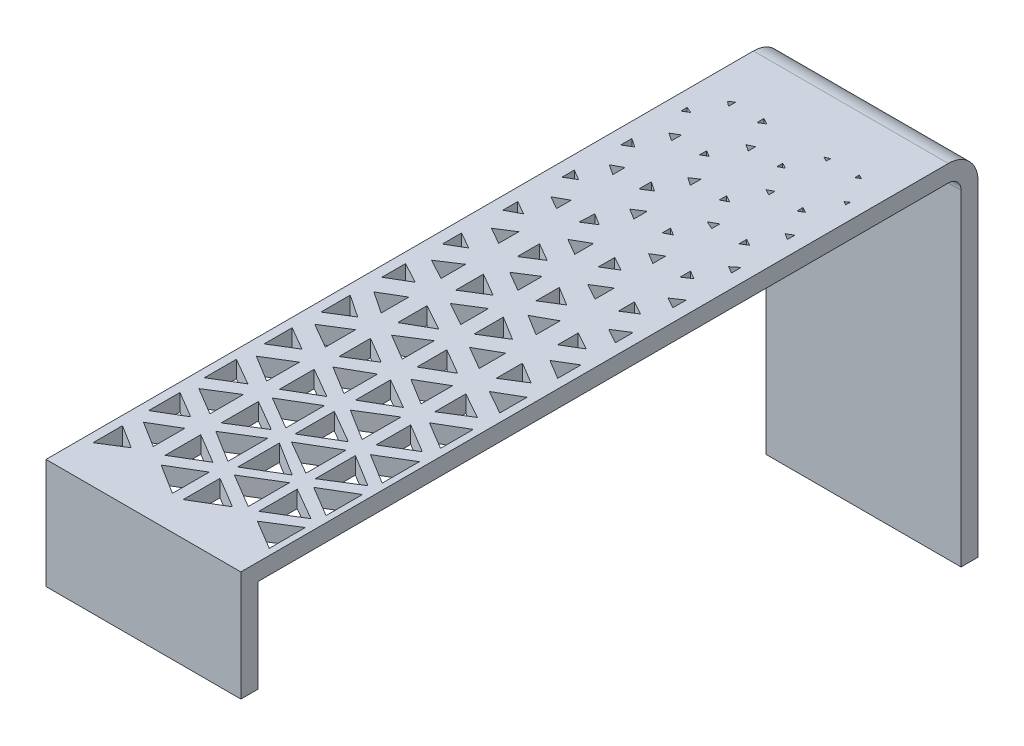
from build123d import *

# Parameters (mm, degrees)
SKETCH1_W           = 23
SKETCH1_H           = 87
BOSS_EXTRUDE1_DEPTH = 42
FILLET1_R           = 3.5
CUT_EXTRUDE1_DEPTH  = 24
SKETCH3_W           = 2
SKETCH3_H           = 40
CUT_EXTRUDE3_DEPTH  = 24
SKETCH4_W           = 83
SKETCH4_H           = 2
CUT_EXTRUDE5_DEPTH  = 24
SKETCH6_W           = 23
SKETCH6_H           = 2
BOSS_EXTRUDE2_DEPTH = 11
CUT_EXTRUDE6_DEPTH  = 2


with BuildPart() as part:
    # Sketch1 → Boss-Extrude1 (new body)
    with BuildSketch(Plane(origin=(0, 0, 0), x_dir=(1, 0, 0), z_dir=(0, 1, 0))):
        with Locations((14.807125307, -11.663390663)):
            Rectangle(SKETCH1_W, SKETCH1_H)
    extrude(amount=BOSS_EXTRUDE1_DEPTH)

    # Fillet1
    fillet1_edges = [part.edges().sort_by_distance(p)[0] for p in [
        (14.807125307, 42, -31.836609337),
    ]]
    fillet(fillet1_edges, radius=FILLET1_R)

    # Sketch2 → Cut-Extrude1 (cut, through all)
    with BuildSketch(Plane(origin=(26.307125307, 0, 0), x_dir=(0, 0, -1), z_dir=(1, 0, 0))):
        with BuildLine():
            Line((29.836609337, 2), (29.836609337, 38.5))
            ThreePointArc((29.836609337, 38.5), (29.397269508, 39.560660172), (28.336609337, 40))
            Line((28.336609337, 40), (-53.163390663, 40))
            Line((-53.163390663, 40), (-53.163390663, 2))
            Line((-53.163390663, 2), (29.836609337, 2))
        make_face()
    extrude(amount=-CUT_EXTRUDE1_DEPTH, mode=Mode.SUBTRACT)

    # Sketch3 → Cut-Extrude3 (cut, through all)
    with BuildSketch(Plane(origin=(26.307125307, 0, 0), x_dir=(0, 0, -1), z_dir=(1, 0, 0))):
        with Locations((-54.163390663, 20)):
            Rectangle(SKETCH3_W, SKETCH3_H)
    extrude(amount=-CUT_EXTRUDE3_DEPTH, mode=Mode.SUBTRACT)

    # Sketch4 → Cut-Extrude5 (cut, through all)
    with BuildSketch(Plane(origin=(26.307125307, 0, 0), x_dir=(0, 0, -1), z_dir=(1, 0, 0))):
        with Locations((-11.663390663, 1)):
            Rectangle(SKETCH4_W, SKETCH4_H)
    extrude(amount=-CUT_EXTRUDE5_DEPTH, mode=Mode.SUBTRACT)

    # Sketch6 → Boss-Extrude2 (add)
    with BuildSketch(Plane.XZ.offset(-40)):
        with Locations((14.807125307, 54.163390663)):
            Rectangle(SKETCH6_W, SKETCH6_H)
    extrude(amount=BOSS_EXTRUDE2_DEPTH)

    # Sketch7 → Cut-Extrude6 (cut)
    with BuildSketch(Plane(origin=(0, 42, 0), x_dir=(1, 0, 0), z_dir=(0, 1, 0))):
        Polygon((4.373025741, -47.203860784), (4.373025741, -50.681960926), (7.147007879, -48.942910855), align=None)
        Polygon((10.680131891, -48.942910855), (14.240933111, -51.175229345), (14.240933111, -46.82714285), align=None)
        Polygon((15.507728284, -46.82714285), (15.507728284, -51.175229345), (19.151354833, -49.001186097), align=None)
        Polygon((22.09300933, -49.001186097), (25.574659446, -51.07858284), (25.574659446, -46.82714285), align=None)
        Polygon((16.017628639, -45.639114235), (20.057709924, -48.049710194), (20.057709924, -43.18389932), align=None)
        Polygon((21.173055855, -43.380049704), (21.173055855, -47.914164474), (25.007184217, -45.584110082), align=None)
        Polygon((21.962994751, -42.225962076), (25.574659446, -44.380934638), (25.574659446, -40.076637523), align=None)
        Polygon((19.434683019, -42.225962076), (15.401886771, -44.625904685), (15.401886771, -39.716859283), align=None)
        Polygon((14.240933111, -39.918335097), (14.240933111, -44.625904685), (10.457774241, -42.272119891), align=None)
        Polygon((9.91671328, -43.504598698), (9.91671328, -47.715752756), (13.454865862, -45.610175727), align=None)
        Polygon((8.322220146, -43.797001873), (8.322220146, -47.517808673), (5.256146085, -45.610175727), align=None)
        Polygon((4.373025741, -44.11682065), (7.492411749, -42.272119891), (4.373025741, -40.415753505), align=None)
        Polygon((5.085620013, -38.905182774), (8.322220146, -40.831304028), (8.322220146, -36.877680696), align=None)
        Polygon((9.91671328, -36.705858486), (9.91671328, -41.095227494), (13.555107042, -38.81603), align=None)
        Polygon((16.017628639, -38.90054299), (20.057709924, -41.243682573), (20.057709924, -36.511788955), align=None)
        Polygon((21.173055855, -36.511788955), (21.173055855, -41.243682573), (24.987036337, -38.854492362), align=None)
        Polygon((21.962994751, -35.530278609), (25.574659446, -37.748711352), (25.574659446, -33.364914894), align=None)
        Polygon((21.303013305, -30.113244689), (21.303013305, -34.213632441), (24.722583325, -32.163438565), align=None)
        Polygon((22.195258476, -28.798102187), (25.460090465, -30.7555233), (25.460090465, -26.874007414), align=None)
        Polygon((21.381965145, -23.686139656), (21.381965145, -27.35601413), (24.481102368, -25.414622886), align=None)
        Polygon((22.521772744, -22.063157282), (25.343157928, -23.63672974), (25.343157928, -20.423731912), align=None)
        Polygon((21.587169292, -17.207284348), (21.587169292, -20.302378453), (24.112880255, -18.720198383), align=None)
        Polygon((22.931533756, -15.31095683), (25.219081627, -16.68120993), (25.219081627, -13.929664465), align=None)
        Polygon((21.78999441, -10.835620554), (21.78999441, -13.260888891), (23.889941826, -11.9928755), align=None)
        Polygon((23.21476035, -8.661215667), (24.987036337, -9.637894958), (24.987036337, -7.541574983), align=None)
        Polygon((21.928662612, -4.335679353), (21.928662612, -6.232617986), (23.523557392, -5.225038412), align=None)
        Polygon((23.523557392, -1.958181357), (24.799839179, -2.669872676), (24.799839179, -1.098028134), align=None)
        Polygon((22.09300933, 2.118032404), (22.09300933, 0.878569452), (23.080046096, 1.543785289), align=None)
        Polygon((23.889941826, 4.819093406), (24.708514938, 4.342856588), (24.708514938, 5.478257439), align=None)
        Polygon((22.167753982, 8.668240856), (22.167753982, 7.762275795), (22.953283382, 8.236602814), align=None)
        Polygon((24.578926953, 11.942487098), (24.578926953, 11.072115254), (23.855167384, 11.522419966), align=None)
        Polygon((22.233407626, 15.253053083), (22.233407626, 14.533509909), (22.863017669, 14.898933035), align=None)
        Polygon((24.041063021, 18.282077068), (24.481102368, 18.034579818), (24.481102368, 18.578642659), align=None)
        Polygon((22.233407626, 21.887378083), (22.233407626, 21.367412528), (22.743245051, 21.664075736), align=None)
        Polygon((19.003489762, 8.668240856), (19.003489762, 7.716775297), (18.028465045, 8.143823796), align=None)
        Polygon((16.519261051, 11.942487098), (16.519261051, 11.072115254), (17.328382384, 11.507301176), align=None)
        Polygon((18.240332563, 14.898933035), (18.919747111, 14.533509909), (18.919747111, 15.253053083), align=None)
        Polygon((16.519261051, 18.578642659), (16.519261051, 17.900689216), (17.169621622, 18.239665938), align=None)
        Polygon((18.861553538, 21.887378083), (18.861553538, 21.367412528), (18.335711671, 21.641488417), align=None)
        Polygon((16.519261051, 5.335788562), (16.519261051, 4.342856588), (17.39552653, 4.799578002), align=None)
        Polygon((19.096098834, 2.195416157), (19.096098834, 0.664455817), (17.845165156, 1.429935987), align=None)
        Polygon((16.228614858, -0.970191589), (16.228614858, -2.901459417), (17.894943581, -1.881787777), align=None)
        Polygon((17.39552653, -5.31212693), (19.32916594, -6.369960411), (19.32916594, -4.113548418), align=None)
        Polygon((10.389248968, -35.530278609), (14.240933111, -37.791834388), (14.240933111, -33.234007387), align=None)
        Polygon((16.017628639, -7.293535955), (16.017628639, -10.037863963), (18.252009038, -8.652869263), align=None)
        Polygon((15.401886771, -33.234007387), (15.401886771, -37.86277333), (19.343446158, -35.512920887), align=None)
        Polygon((4.306147659, -33.691236831), (4.306147659, -37.47024358), (7.492411749, -35.530278609), align=None)
        Polygon((9.91671328, -34.213632441), (13.454865862, -32.163438565), (9.91671328, -30.121294465), align=None)
        Polygon((8.322220146, -30.264520369), (8.322220146, -34.132852243), (5.1676151, -32.198686306), align=None)
        Polygon((4.373025741, -27.176559978), (4.373025741, -30.486967872), (7.147007879, -28.786171201), align=None)
        Polygon((19.930328421, -29.876058228), (19.930328421, -34.475602674), (16.228614858, -32.163438565), align=None)
        Polygon((15.507728284, -26.695064873), (15.507728284, -30.843252154), (19.096098834, -28.763959316), align=None)
        Polygon((14.149392865, -26.874007414), (14.149392865, -30.843252154), (10.794314675, -28.786171201), align=None)
        Polygon((19.771131554, -23.63672974), (19.771131554, -27.35601413), (16.655256244, -25.445594346), align=None)
        Polygon((15.752445363, -20.302378453), (15.752445363, -23.83714891), (18.796870014, -22.069763682), align=None)
        Polygon((16.852340946, -18.720198383), (19.577738856, -20.302378453), (19.577738856, -17.163959593), align=None)
        Polygon((15.752445363, -13.629405346), (15.752445363, -17.098387514), (18.559407138, -15.36389643), align=None)
        Polygon((19.482614442, -10.655702339), (19.482614442, -13.506041775), (17.033827053, -11.9928755), align=None)
        Polygon((10.081927259, -23.63672974), (10.081927259, -27.35601413), (13.159201825, -25.454490089), align=None)
        Polygon((11.007541373, -22.069763682), (14.084815939, -23.887524031), (14.084815939, -20.115663305), align=None)
        Polygon((10.081927259, -16.957013986), (10.081927259, -20.423731912), (13.159201825, -18.666566829), align=None)
        Polygon((11.227358204, -15.36389643), (13.999248144, -16.903795527), (13.999248144, -13.629405346), align=None)
        Polygon((10.181794454, -10.411025865), (10.181794454, -13.692981158), (12.898733051, -11.9928755), align=None)
        Polygon((13.879314173, -7.184466196), (13.879314173, -10.037863963), (11.540263753, -8.676027498), align=None)
        Polygon((10.389248968, -3.995907316), (10.389248968, -6.61934726), (12.546178656, -5.243920368), align=None)
        Polygon((11.620564542, -1.881787777), (13.555107042, -3.001126206), (13.555107042, -0.769730825), align=None)
        Polygon((10.6000548, 2.316782854), (10.497129788, 0.536785585), (11.966913873, 1.474034754), align=None)
        Polygon((12.17321812, 4.868307512), (13.428996104, 4.094047363), (13.428996104, 5.67416604), align=None)
        Polygon((10.654642732, 8.93139351), (10.654642732, 7.454106399), (11.778351048, 8.175213108), align=None)
        Polygon((12.388055992, 11.507301176), (13.317669608, 10.881733501), (13.317669608, 12.141063128), align=None)
        Polygon((10.745610618, 15.363590955), (10.745610618, 14.533509909), (11.467713812, 14.948605404), align=None)
        Polygon((13.222298165, 18.65779809), (13.222298165, 17.797338249), (12.444901912, 18.320473838), align=None)
        Polygon((10.827736388, 22.04738766), (10.827736388, 21.210447951), (11.55822472, 21.658328312), align=None)
        Polygon((7.492411749, 22.04738766), (7.492411749, 21.210447951), (6.909019154, 21.658328312), align=None)
        Polygon((5.1676151, 18.65779809), (5.1676151, 17.900689216), (5.899279704, 18.34929078), align=None)
        Polygon((7.647677873, 15.497671081), (7.647677873, 14.315981033), (6.70765947, 14.948550432), align=None)
        Polygon((7.647677873, 8.849973381), (7.647677873, 7.385971226), (6.448778822, 8.192749955), align=None)
        Polygon((5.085620013, 12.203010575), (5.085620013, 10.881733501), (6.112596945, 11.511398315), align=None)
        Polygon((5.347959752, -25.496371935), (8.322220146, -27.205649913), (8.322220146, -23.63672974), align=None)
        Polygon((4.469230136, -20.423731912), (4.469230136, -23.887524031), (7.147007879, -22.213256206), align=None)
        Polygon((5.533447402, -18.690372949), (8.127181428, -20.423731912), (8.127181428, -17.163959593), align=None)
        Polygon((4.509198681, -13.929664465), (4.509198681, -16.725320339), (6.987905663, -15.266600437), align=None)
        Polygon((5.701870183, -12.052003512), (8.127181428, -13.360139516), (8.127181428, -10.457782873), align=None)
        Polygon((4.682583647, -7.492624581), (4.682583647, -9.765638038), (6.644303768, -8.611165079), align=None)
        Polygon((5.964757747, -5.243920368), (7.93667039, -6.368272474), (7.93667039, -3.995907316), align=None)
        Polygon((4.792199024, -0.970191589), (4.792199024, -2.731753146), (6.400380029, -1.881787777), align=None)
        Polygon((6.257882978, 1.474034754), (7.805385105, 0.596834342), (7.805385105, 2.316782854), align=None)
        Polygon((4.909232662, 5.588671043), (4.909232662, 4.13628122), (6.14320801, 4.862476132), align=None)
    extrude(amount=-CUT_EXTRUDE6_DEPTH, mode=Mode.SUBTRACT)


solid = part.part
